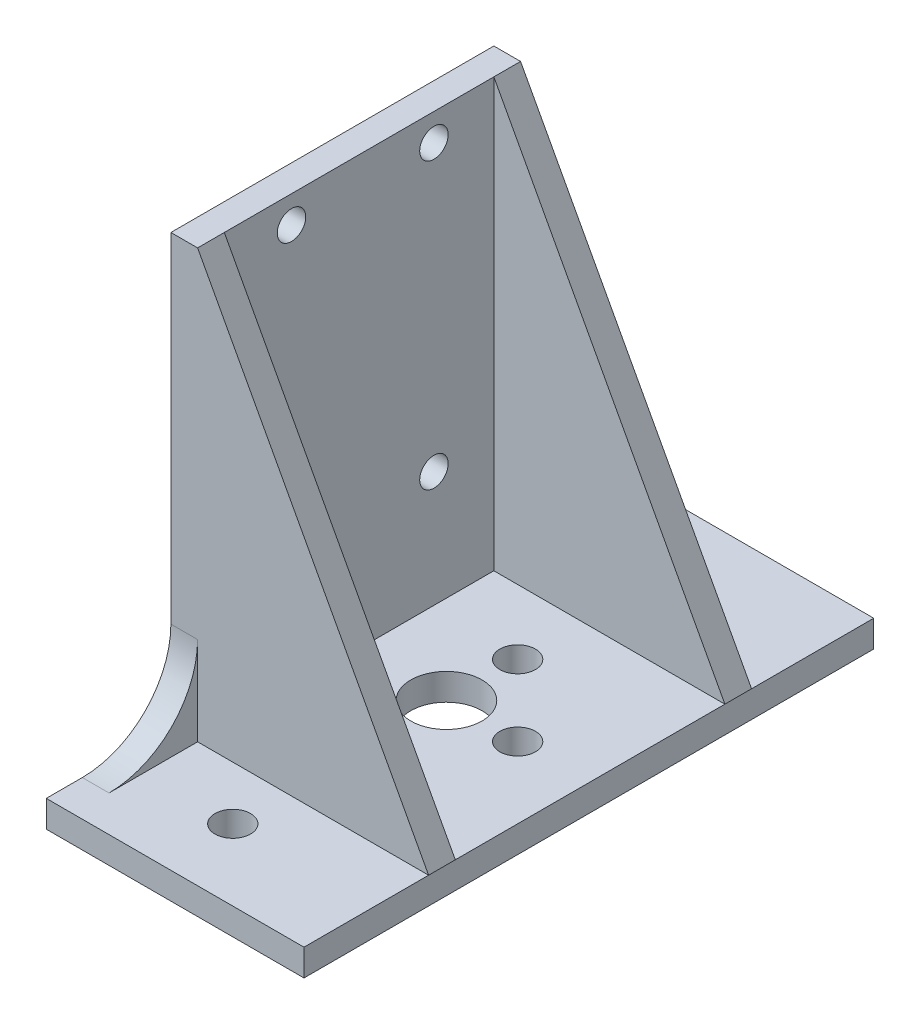
from build123d import *

# Parameters (mm, degrees)
SKETCH1_W           = 28.95
SKETCH1_H           = 64
SKETCH1_R           = 2
SKETCH1_R_2         = 4
BOSS_EXTRUDE1_DEPTH = 3
SKETCH2_R           = 1.6
BOSS_EXTRUDE2_DEPTH = 3
RIB1_REACH          = 75.226
SKETCH3_WALL_W      = 203.062325646
SKETCH3_WALL_H      = 3
RIB2_REACH          = 75.416
SKETCH4_WALL_W      = 203.442532142
SKETCH4_WALL_H      = 3


with BuildPart() as part:
    # Sketch1 → Boss-Extrude1 (new body)
    with BuildSketch(Plane(origin=(0, 0, 0), x_dir=(1, 0, 0), z_dir=(0, 1, 0))):
        with Locations((1.525, 0)):
            Rectangle(SKETCH1_W, SKETCH1_H)
        with Locations(Location((0, -24, 0), (0, 0, 270))):
            Circle(SKETCH1_R, mode=Mode.SUBTRACT)
        with Locations(Location((0, 24, 0), (0, 0, 270))):
            Circle(SKETCH1_R, mode=Mode.SUBTRACT)
        with Locations((0, 16)):
            Circle(SKETCH1_R_2, mode=Mode.SUBTRACT)
        with Locations(Location((0, -8, 0), (0, 0, 270))):
            Circle(SKETCH1_R, mode=Mode.SUBTRACT)
        with Locations(Location((8, 0, 0), (0, 0, 270))):
            Circle(SKETCH1_R, mode=Mode.SUBTRACT)
        with Locations(Location((0, 8, 0), (0, 0, 270))):
            Circle(SKETCH1_R, mode=Mode.SUBTRACT)
        with Locations(Location((0, 0, 0), (0, 0, 270))):
            Circle(SKETCH1_R_2, mode=Mode.SUBTRACT)
        with Locations((0, -16)):
            Circle(SKETCH1_R_2, mode=Mode.SUBTRACT)
        with Locations((0, -16)):
            Circle(SKETCH1_R_2)
        with Locations((0, 16)):
            Circle(SKETCH1_R_2)
    extrude(amount=BOSS_EXTRUDE1_DEPTH)

    # Sketch2 → Boss-Extrude2 (add)
    with BuildSketch(Plane.ZY.offset(12.95)):
        with BuildLine():
            Line((18, 51.05), (18, 12.95))
            ThreePointArc((18, 12.95), (20.914287527, 5.914287527), (27.95, 3))
            Line((27.95, 3), (32, 3))
            Line((32, 3), (32, 0))
            Line((32, 0), (-32, 0))
            Line((-32, 0), (-32, 3))
            Line((-32, 3), (-28.228, 3))
            ThreePointArc((-28.228, 3), (-21.192287527, 5.914287527), (-18.278, 12.95))
            Line((-18.278, 12.95), (-18.278, 51.05))
            Line((-18.278, 51.05), (18, 51.05))
        make_face()
        with Locations((-8.548, 48)):
            Circle(SKETCH2_R, mode=Mode.SUBTRACT)
        with Locations((-8.548, 16)):
            Circle(SKETCH2_R, mode=Mode.SUBTRACT)
        with Locations((7.452, 16)):
            Circle(SKETCH2_R, mode=Mode.SUBTRACT)
        with Locations((7.452, 48)):
            Circle(SKETCH2_R, mode=Mode.SUBTRACT)
    extrude(amount=-BOSS_EXTRUDE2_DEPTH)

    # Sketch3 wall → Rib1 (add, up to next)
    with BuildSketch(Plane(origin=(3.025, 27.025, 18), x_dir=(0.475191447028, -0.879882428891, 0), z_dir=(0.879882428891, 0.475191447028, 0)), mode=Mode.PRIVATE) as rib1_sk1:
        with Locations((0, 1.5)):
            Rectangle(SKETCH3_WALL_W, SKETCH3_WALL_H)
    rib1_tool1 = extrude(rib1_sk1.sketch, amount=-RIB1_REACH, mode=Mode.PRIVATE) - part.part
    add(rib1_tool1.solids().sort_by_distance((3.025, 27.025, 18))[0])

    # Sketch4 wall → Rib2 (add, up to next)
    with BuildSketch(Plane(origin=(3.025, 27.025, -18.278), x_dir=(0.475191447028, -0.879882428891, 0), z_dir=(-0.879882428891, -0.475191447028, 0)), mode=Mode.PRIVATE) as rib2_sk1:
        with Locations((0, 1.5)):
            Rectangle(SKETCH4_WALL_W, SKETCH4_WALL_H)
    rib2_tool1 = extrude(rib2_sk1.sketch, amount=RIB2_REACH, mode=Mode.PRIVATE) - part.part
    add(rib2_tool1.solids().sort_by_distance((3.025, 27.025, -18.278))[0])


solid = part.part
